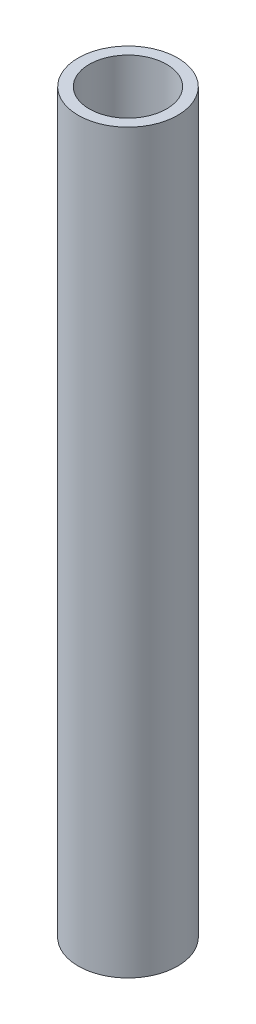
from build123d import *

# Parameters (mm, degrees)
SKETCH1_R           = 13.5
SKETCH1_R_2         = 10.5
BOSS_EXTRUDE2_DEPTH = 200


with BuildPart() as part:
    # Sketch1 → Boss-Extrude2 (new body)
    with BuildSketch(Plane(origin=(0, 0, 0), x_dir=(1, 0, 0), z_dir=(0, 1, 0))):
        Circle(SKETCH1_R)
        Circle(SKETCH1_R_2, mode=Mode.SUBTRACT)
    extrude(amount=BOSS_EXTRUDE2_DEPTH)


solid = part.part
